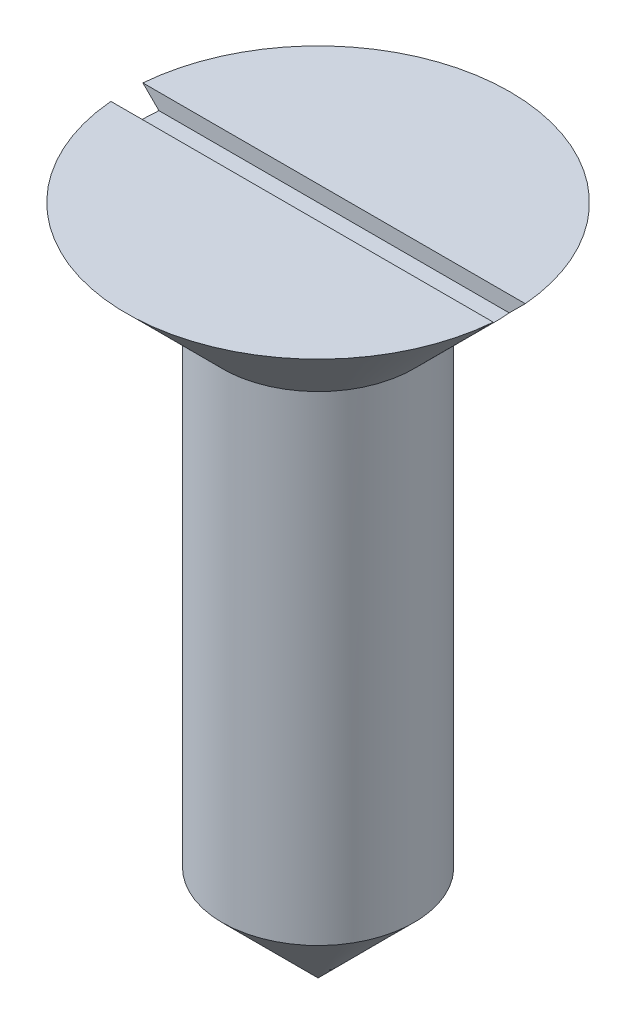
from build123d import *

# Parameters (mm, degrees)
SKETCH2_W          = 2
SKETCH2_H          = 2
CUT_EXTRUDE1_DEPTH = 50


with BuildPart() as part:
    # Sketch1 → Revolve2 (revolve)
    with BuildSketch(Plane.XY):
        Polygon((12, 12.4), (0, 12.4), (0, 6.48), (0, -29.6), (6, -23.6), (6, 6.4), align=None)
    revolve(axis=Axis((0, -39.28, 0), (0, 1, 0)))

    # Sketch2 → Cut-Extrude1 (cut, symmetric)
    with BuildSketch(Plane(origin=(0, 0, 0), x_dir=(0, 0, -1), z_dir=(1, 0, 0))):
        with Locations((0, 12.4)):
            Rectangle(SKETCH2_W, SKETCH2_H)
    extrude(amount=CUT_EXTRUDE1_DEPTH, both=True, mode=Mode.SUBTRACT)


solid = part.part
